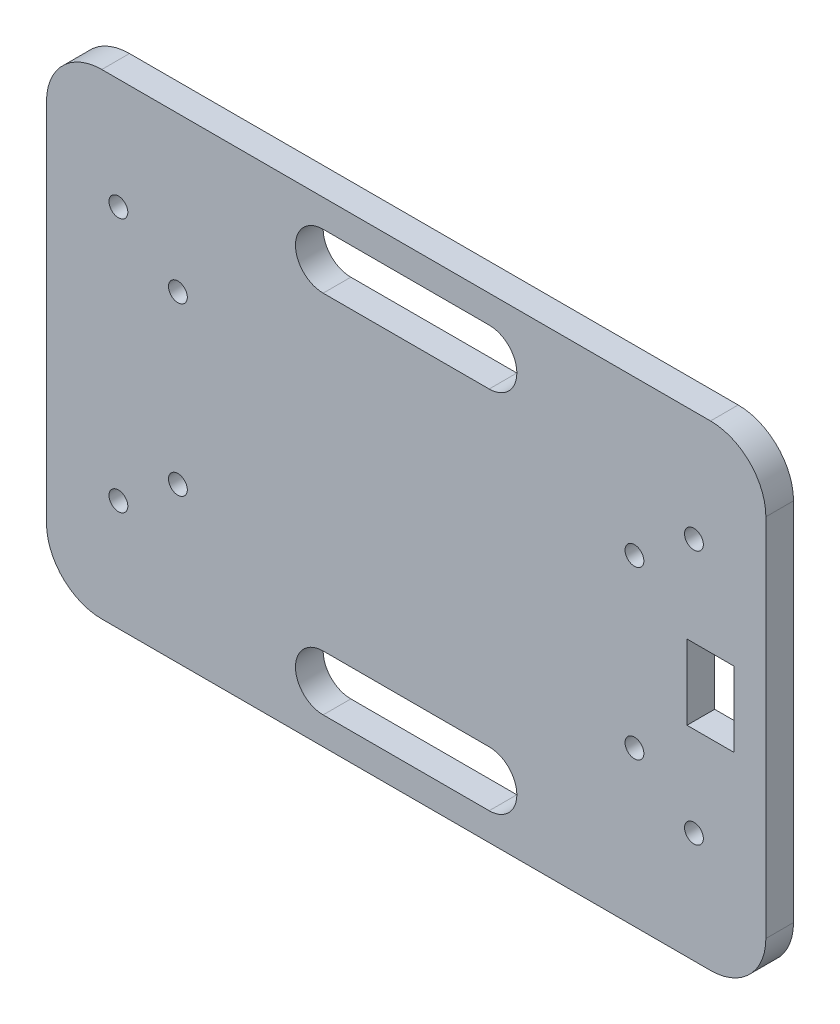
from build123d import *

# Parameters (mm, degrees)
BOSS_EXTRUDE1_DEPTH = 5
SKETCH2_R           = 1.7
SKETCH2_W           = 8.5
SKETCH2_H           = 13.5
CUT_EXTRUDE2_DEPTH  = 5


with BuildPart() as part:
    # Sketch1 → Boss-Extrude1 (new body)
    with BuildSketch(Plane.XY):
        with BuildLine():
            Line((-55, 43), (55, 43))
            ThreePointArc((55, 43), (62.071067812, 40.071067812), (65, 33))
            Line((65, 33), (65, -33))
            ThreePointArc((65, -33), (62.071067812, -40.071067812), (55, -43))
            Line((55, -43), (-55, -43))
            ThreePointArc((-55, -43), (-62.071067812, -40.071067812), (-65, -33))
            Line((-65, -33), (-65, 33))
            ThreePointArc((-65, 33), (-62.071067812, 40.071067812), (-55, 43))
        make_face()
    extrude(amount=BOSS_EXTRUDE1_DEPTH)

    # Sketch2 → Cut-Extrude2 (cut)
    with BuildSketch(Plane.XY.offset(5)):
        with Locations((-52, 23)):
            Circle(SKETCH2_R)
        with Locations((-52, -23)):
            Circle(SKETCH2_R)
        with Locations((52, -23)):
            Circle(SKETCH2_R)
        with Locations((52, 23)):
            Circle(SKETCH2_R)
        with Locations((-41.25, -15.05)):
            Circle(SKETCH2_R)
        with Locations((-41.25, 15.075)):
            Circle(SKETCH2_R)
        with Locations((41.25, -15.05)):
            Circle(SKETCH2_R)
        with Locations((41.25, 15.075)):
            Circle(SKETCH2_R)
        with BuildLine():
            Line((-15, -28), (15, -28))
            ThreePointArc((15, -28), (20, -33), (15, -38))
            Line((15, -38), (-15, -38))
            ThreePointArc((-15, -38), (-20, -33), (-15, -28))
        make_face()
        with BuildLine():
            Line((-15, 38), (15, 38))
            ThreePointArc((15, 38), (20, 33), (15, 28))
            Line((15, 28), (-15, 28))
            ThreePointArc((-15, 28), (-20, 33), (-15, 38))
        make_face()
        with Locations((55, 0)):
            Rectangle(SKETCH2_W, SKETCH2_H)
    extrude(amount=-CUT_EXTRUDE2_DEPTH, mode=Mode.SUBTRACT)


solid = part.part
